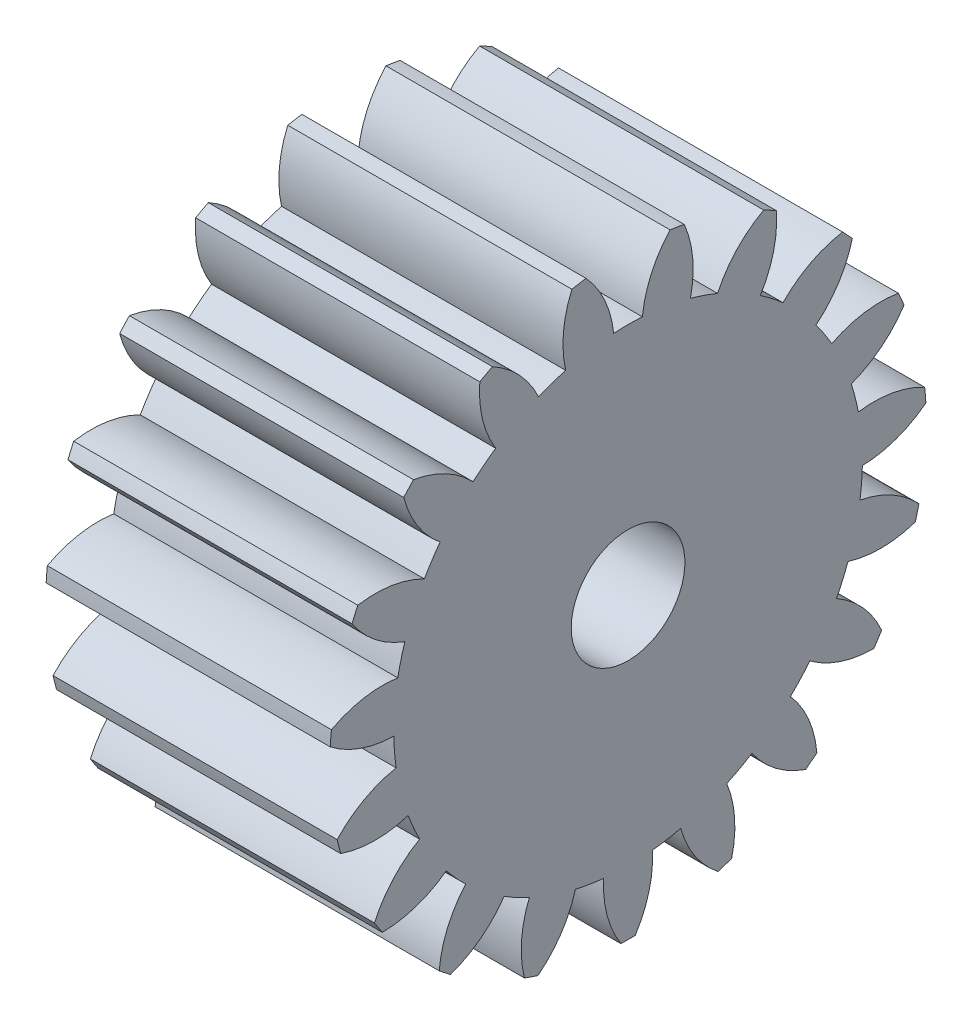
from build123d import *

# Parameters (mm, degrees)
BASPROSKE_W     = 5
BASPROSKE_H     = 5.25
TOOTHCUT_DEPTH  = 9.951256895
TEETHCUTS_COUNT = 19
TEETHCUTS_ANGLE = 341.052631579
BORSKE_R        = 1
BORE_DEPTH      = 50.0000508


with BuildPart() as part:
    # BasProSke → Base-Revolve (revolve)
    with BuildSketch(Plane(origin=(0, 0, 0), x_dir=(1, 0, 0), z_dir=(0, 1, 0)), mode=Mode.PRIVATE) as base_revolve_sk:
        with Locations((2.5, 2.625)):
            Rectangle(BASPROSKE_W, BASPROSKE_H)
    revolve(base_revolve_sk.sketch.rotate(Axis((-10, 0, 0), (1, 0, 0)), 180), axis=Axis((-10, 0, 0), (1, 0, 0)))

    # TooCutSke → ToothCut (cut, through all)
    with BuildSketch(Plane(origin=(0, 0, 0), x_dir=(0, 0, -1), z_dir=(1, 0, 0))):
        with BuildLine():
            ThreePointArc((0.252459579, 4.116265317), (0, 4.124), (-0.252459579, 4.116265317))
            ThreePointArc((-0.252459579, 4.116265317), (-0.415709164, 4.709991477), (-0.760260085, 5.220330427))
            ThreePointArc((-0.760260085, 5.220330427), (0, 5.2754), (0.760260085, 5.220330427))
            ThreePointArc((0.760260085, 5.220330427), (0.415709164, 4.709991477), (0.252459579, 4.116265317))
        make_face()
    toothcut = extrude(amount=TOOTHCUT_DEPTH, mode=Mode.SUBTRACT)

    # TeethCuts: ToothCut ×19 about axis
    teethcuts_axis = Axis((-10, 0, 0), (1, 0, 0))
    for i in range(1, TEETHCUTS_COUNT):
        add(toothcut.rotate(teethcuts_axis, i * TEETHCUTS_ANGLE / (TEETHCUTS_COUNT - 1)), mode=Mode.SUBTRACT)

    # BorSke → Bore (cut, symmetric)
    with BuildSketch(Plane(origin=(0, 0, 0), x_dir=(0, 0, -1), z_dir=(1, 0, 0))):
        with Locations(Location((0, 0, 0), (0, 0, 180))):
            Circle(BORSKE_R)
    extrude(amount=BORE_DEPTH, both=True, mode=Mode.SUBTRACT)


solid = part.part
